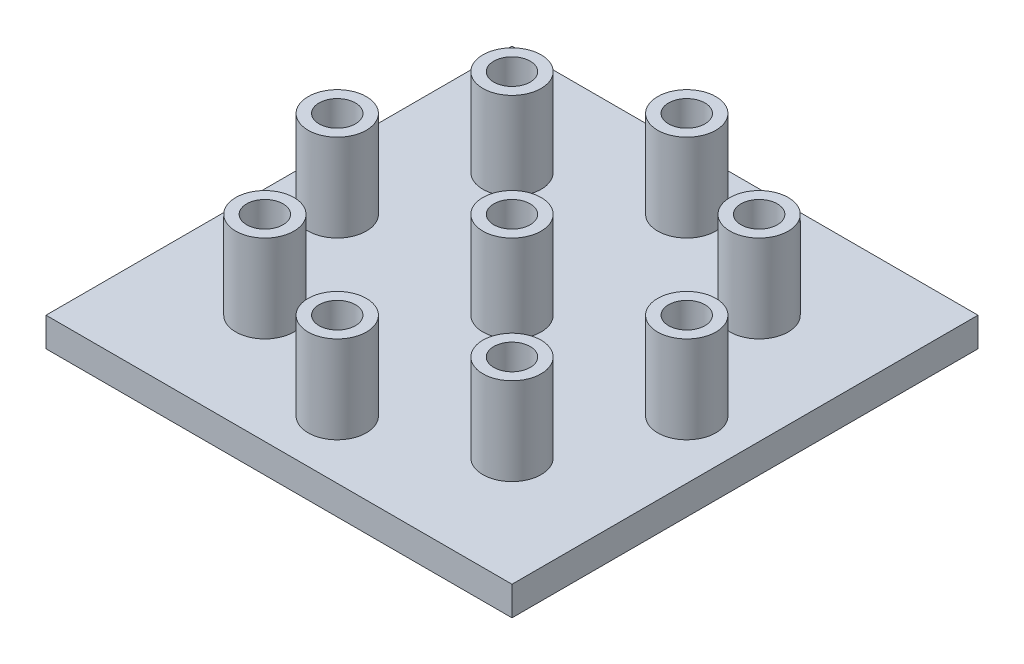
from build123d import *

# Parameters (mm, degrees)
SKETCH1_W           = 50.8
SKETCH1_H           = 50.8
BOSS_EXTRUDE1_DEPTH = 3.175
SKETCH2_R           = 3.175
BOSS_EXTRUDE2_DEPTH = 9.525
SKETCH3_R           = 1.98374
CUT_EXTRUDE1_DEPTH  = 13.7


with BuildPart() as part:
    # Sketch1 → Boss-Extrude1 (new body)
    with BuildSketch(Plane(origin=(0, 0, 0), x_dir=(1, 0, 0), z_dir=(0, 1, 0))):
        Rectangle(SKETCH1_W, SKETCH1_H)
    extrude(amount=BOSS_EXTRUDE1_DEPTH)

    # Sketch2 → Boss-Extrude2 (add)
    with BuildSketch(Plane(origin=(0, 3.175, 0), x_dir=(1, 0, 0), z_dir=(0, 1, 0))):
        with Locations((0, 19.05)):
            Circle(SKETCH2_R)
        with Locations((13.470384182, 13.470384182)):
            Circle(SKETCH2_R)
        with Locations((19.05, 0)):
            Circle(SKETCH2_R)
        with Locations((13.470384182, -13.470384182)):
            Circle(SKETCH2_R)
        with Locations((0, -19.05)):
            Circle(SKETCH2_R)
        with Locations((-13.470384182, -13.470384182)):
            Circle(SKETCH2_R)
        with Locations((-19.05, 0)):
            Circle(SKETCH2_R)
        with Locations((-13.470384182, 13.470384182)):
            Circle(SKETCH2_R)
        Circle(SKETCH2_R)
    extrude(amount=BOSS_EXTRUDE2_DEPTH)

    # Sketch3 → Cut-Extrude1 (cut, through all)
    with BuildSketch(Plane(origin=(0, 12.7, 0), x_dir=(1, 0, 0), z_dir=(0, 1, 0))):
        with Locations((0, 19.05)):
            Circle(SKETCH3_R)
        with Locations((13.470384182, 13.470384182)):
            Circle(SKETCH3_R)
        with Locations((19.05, 0)):
            Circle(SKETCH3_R)
        with Locations((13.470384182, -13.470384182)):
            Circle(SKETCH3_R)
        with Locations((0, -19.05)):
            Circle(SKETCH3_R)
        with Locations((-13.470384182, -13.470384182)):
            Circle(SKETCH3_R)
        with Locations((-19.05, 0)):
            Circle(SKETCH3_R)
        with Locations((-13.470384182, 13.470384182)):
            Circle(SKETCH3_R)
        Circle(SKETCH3_R)
    extrude(amount=-CUT_EXTRUDE1_DEPTH, mode=Mode.SUBTRACT)


solid = part.part
